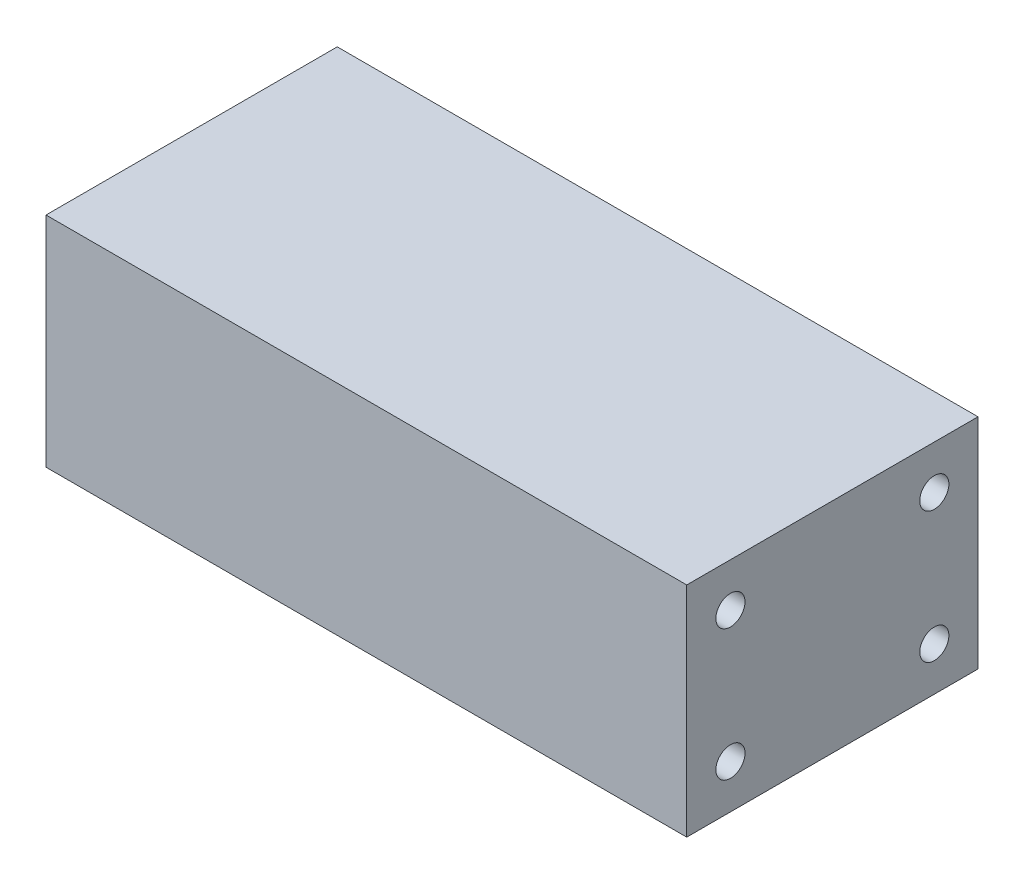
from build123d import *

# Parameters (mm, degrees)
SKETCH1_W           = 20
SKETCH1_H           = 15
BOSS_EXTRUDE1_DEPTH = 44
SKETCH1_3_R         = 1
CUT_EXTRUDE1_DEPTH  = 5
CUT_EXTRUDE2_START  = -5
SKETCH2_R           = 1
CUT_EXTRUDE2_DEPTH  = 5


with BuildPart() as part:
    # Sketch1 → Boss-Extrude1 (new body)
    with BuildSketch(Plane(origin=(0, 0, 0), x_dir=(0, 0, -1), z_dir=(1, 0, 0))):
        with Locations((10, 7.5)):
            Rectangle(SKETCH1_W, SKETCH1_H)
    extrude(amount=-BOSS_EXTRUDE1_DEPTH)

    # Sketch1_3 → Cut-Extrude1 (cut)
    with BuildSketch(Plane(origin=(0, 0, 0), x_dir=(0, 0, -1), z_dir=(1, 0, 0))):
        with Locations((3, 12)):
            Circle(SKETCH1_3_R)
        with Locations((17, 12)):
            Circle(SKETCH1_3_R)
        with Locations((17, 3)):
            Circle(SKETCH1_3_R)
        with Locations((3, 3)):
            Circle(SKETCH1_3_R)
    extrude(amount=-CUT_EXTRUDE1_DEPTH, mode=Mode.SUBTRACT)

    # Sketch2 → Cut-Extrude2 (cut)
    with BuildSketch(Plane.ZY.offset(44).offset(CUT_EXTRUDE2_START)):
        with Locations((-17, 12)):
            Circle(SKETCH2_R)
        with Locations((-3, 12)):
            Circle(SKETCH2_R)
        with Locations((-3, 3)):
            Circle(SKETCH2_R)
        with Locations((-17, 3)):
            Circle(SKETCH2_R)
    extrude(amount=CUT_EXTRUDE2_DEPTH, mode=Mode.SUBTRACT)


solid = part.part
